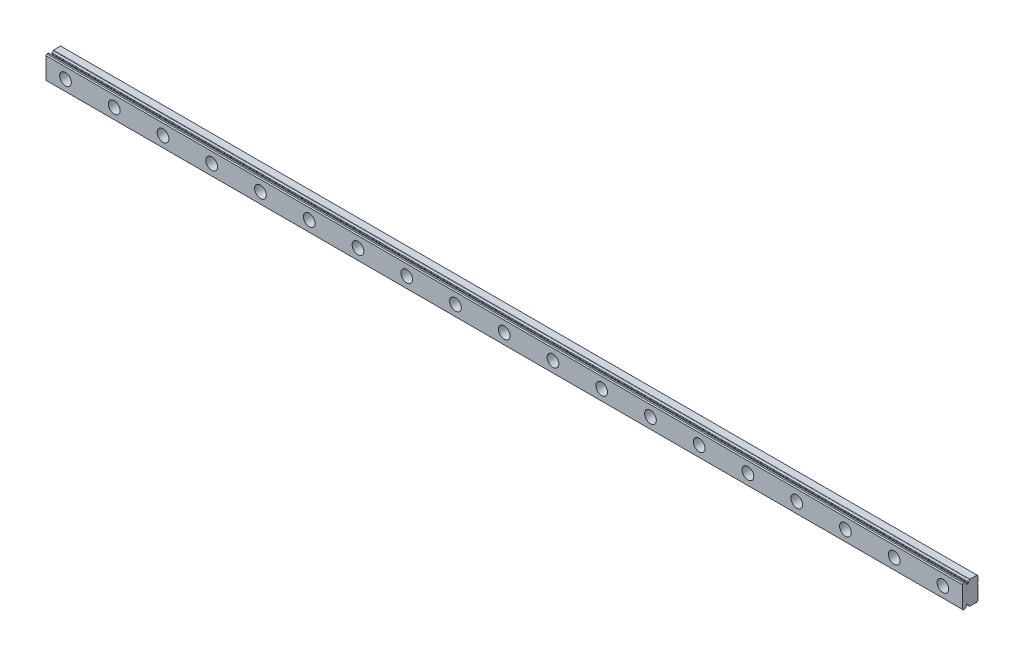
from build123d import *

# Parameters (mm, degrees)
BOSS_EXTRUDE1_DEPTH                              = 470
CBORE_FOR_M3_HEX_HEAD_MACHINE_SCREW2_D           = 3.5
CBORE_FOR_M3_HEX_HEAD_MACHINE_SCREW2_DEPTH       = 7.999998
CBORE_FOR_M3_HEX_HEAD_MACHINE_SCREW2_CBORE_D     = 6
CBORE_FOR_M3_HEX_HEAD_MACHINE_SCREW2_CBORE_DEPTH = 4.499998
LPATTERN2_COUNT                                  = 19
LPATTERN2_PITCH                                  = 25


with BuildPart() as part:
    # Sketch1 → Boss-Extrude1 (new body)
    with BuildSketch(Plane(origin=(-10, 0, 0), x_dir=(0, -1, 0), z_dir=(-1, 0, 0))):
        with BuildLine():
            Line((5.5, 0), (6, 0.5))
            Line((6, 0.5), (6, 4.142118421))
            ThreePointArc((6, 4.142118421), (5.9576137, 4.281389924), (5.844827586, 4.373435797))
            ThreePointArc((5.844827586, 4.373435797), (5.51524529, 4.575926598), (5.267205011, 4.87274815))
            ThreePointArc((5.267205011, 4.87274815), (5.185241933, 4.957012877), (5.073828324, 4.994502855))
            Line((5.073828324, 4.994502855), (4.728211064, 5.024740447))
            ThreePointArc((4.728211064, 5.024740447), (4.565680666, 5.10489157), (4.5, 5.273789122))
            Line((4.5, 5.273789122), (4.5, 5.726210879))
            ThreePointArc((4.5, 5.726210879), (4.565680666, 5.89510843), (4.728211064, 5.975259553))
            Line((4.728211064, 5.975259553), (5.09477657, 6.007329879))
            ThreePointArc((5.09477657, 6.007329879), (5.203244499, 6.042993575), (5.284541491, 6.123168322))
            ThreePointArc((5.284541491, 6.123168322), (5.527906161, 6.402383779), (5.844827586, 6.594082617))
            ThreePointArc((5.844827586, 6.594082617), (5.9576137, 6.68612849), (6, 6.825399994))
            Line((6, 6.825399994), (6, 7.499998))
            Line((6, 7.499998), (5.5, 7.999998))
            Line((5.5, 7.999998), (-5.5, 7.999998))
            Line((-5.5, 7.999998), (-6, 7.499998))
            Line((-6, 7.499998), (-6, 6.825399994))
            ThreePointArc((-6, 6.825399994), (-5.9576137, 6.68612849), (-5.844827586, 6.594082617))
            ThreePointArc((-5.844827586, 6.594082617), (-5.527906161, 6.402383779), (-5.284541491, 6.123168322))
            ThreePointArc((-5.284541491, 6.123168322), (-5.203244499, 6.042993575), (-5.09477657, 6.007329879))
            Line((-5.09477657, 6.007329879), (-4.728211064, 5.975259553))
            ThreePointArc((-4.728211064, 5.975259553), (-4.565680666, 5.89510843), (-4.5, 5.726210879))
            Line((-4.5, 5.726210879), (-4.5, 5.273789122))
            ThreePointArc((-4.5, 5.273789122), (-4.565680666, 5.10489157), (-4.728211064, 5.024740447))
            Line((-4.728211064, 5.024740447), (-5.073828324, 4.994502855))
            ThreePointArc((-5.073828324, 4.994502855), (-5.185241933, 4.957012877), (-5.267205011, 4.87274815))
            ThreePointArc((-5.267205011, 4.87274815), (-5.51524529, 4.575926598), (-5.844827586, 4.373435797))
            ThreePointArc((-5.844827586, 4.373435797), (-5.9576137, 4.281389924), (-6, 4.142118421))
            Line((-6, 4.142118421), (-6, 0.5))
            Line((-6, 0.5), (-5.5, 0))
            Line((-5.5, 0), (-2.4, 0))
            ThreePointArc((-2.4, 0), (-2, 0.2), (-1.6, 0))
            Line((-1.6, 0), (5.5, 0))
        make_face()
    extrude(amount=-BOSS_EXTRUDE1_DEPTH)

    # CBORE for M3 Hex Head Machine Screw2
    with Locations(Plane.XY.offset(7.999998)):
        with Locations((0, 0)):
            cbore_for_m3_hex_head_machine_screw2 = CounterBoreHole(CBORE_FOR_M3_HEX_HEAD_MACHINE_SCREW2_D / 2, CBORE_FOR_M3_HEX_HEAD_MACHINE_SCREW2_CBORE_D / 2, CBORE_FOR_M3_HEX_HEAD_MACHINE_SCREW2_CBORE_DEPTH, depth=CBORE_FOR_M3_HEX_HEAD_MACHINE_SCREW2_DEPTH)

    # LPattern2: CBORE for M3 Hex Head Machine Screw2 ×19
    with Locations(*[(i * LPATTERN2_PITCH, 0, 0) for i in range(1, LPATTERN2_COUNT)]):
        add(cbore_for_m3_hex_head_machine_screw2, mode=Mode.SUBTRACT)


solid = part.part
